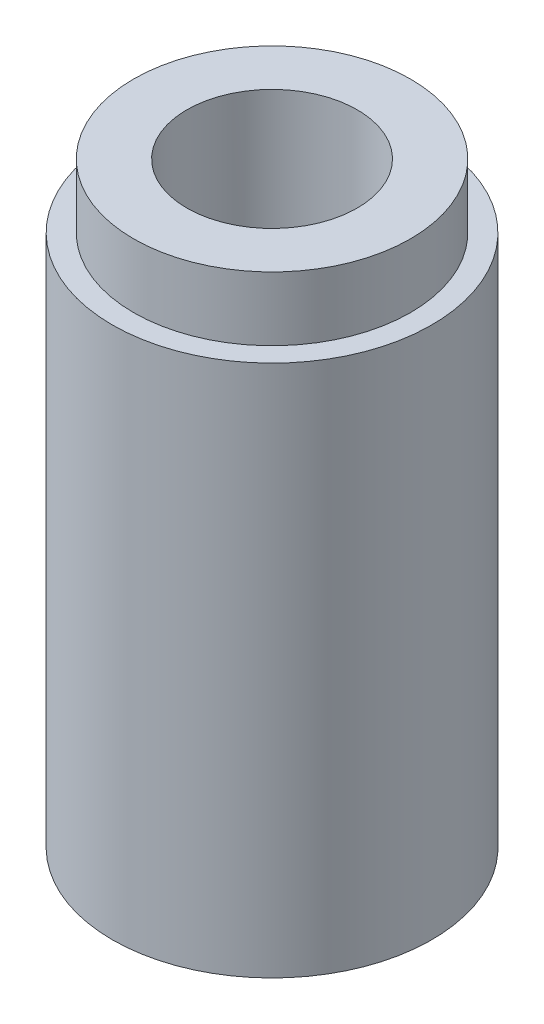
from build123d import *

# Parameters (mm, degrees)
SKETCH1_R           = 7.5
BOSS_EXTRUDE1_DEPTH = 25
SKETCH2_R           = 6.5
BOSS_EXTRUDE2_DEPTH = 3
SKETCH3_R           = 5.1
CUT_EXTRUDE1_DEPTH  = 7
SKETCH4_R           = 4
CUT_EXTRUDE2_DEPTH  = 29


with BuildPart() as part:
    # Sketch1 → Boss-Extrude1 (new body)
    with BuildSketch(Plane(origin=(0, 0, 0), x_dir=(1, 0, 0), z_dir=(0, 1, 0))):
        Circle(SKETCH1_R)
    extrude(amount=BOSS_EXTRUDE1_DEPTH)

    # Sketch2 → Boss-Extrude2 (add)
    with BuildSketch(Plane(origin=(0, 25, 0), x_dir=(1, 0, 0), z_dir=(0, 1, 0))):
        Circle(SKETCH2_R)
    extrude(amount=BOSS_EXTRUDE2_DEPTH)

    # Sketch3 → Cut-Extrude1 (cut)
    with BuildSketch(Plane.XZ):
        Circle(SKETCH3_R)
    extrude(amount=-CUT_EXTRUDE1_DEPTH, mode=Mode.SUBTRACT)

    # Sketch4 → Cut-Extrude2 (cut, through all)
    with BuildSketch(Plane(origin=(0, 28, 0), x_dir=(1, 0, 0), z_dir=(0, 1, 0))):
        Circle(SKETCH4_R)
    extrude(amount=-CUT_EXTRUDE2_DEPTH, mode=Mode.SUBTRACT)


solid = part.part
